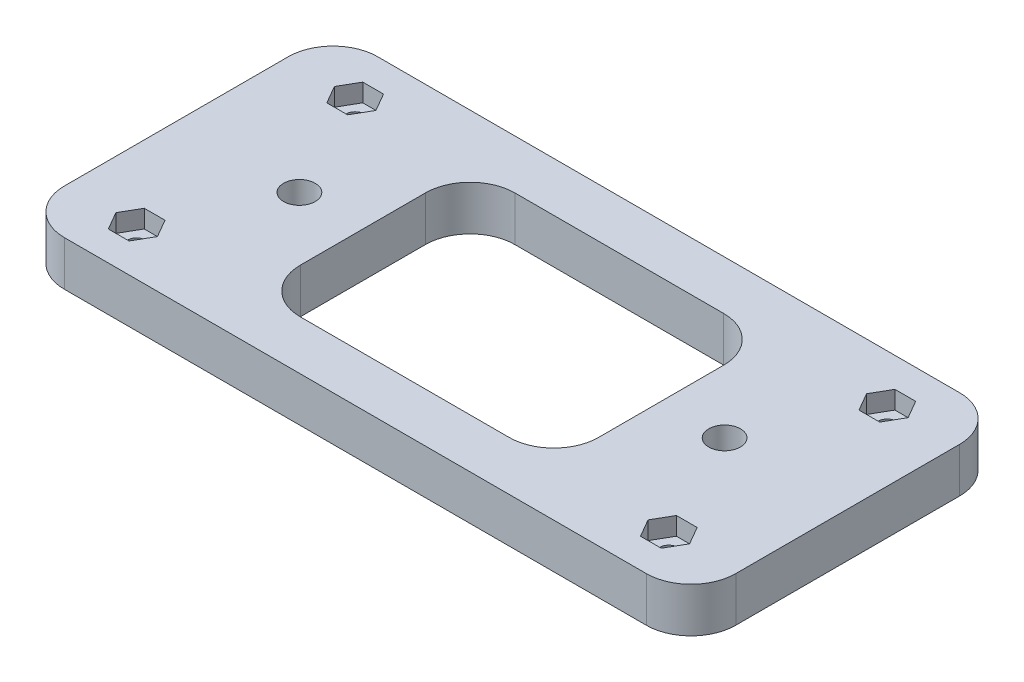
from build123d import *

# Parameters (mm, degrees)
SKETCH1_R                                         = 1.3
BOSS_EXTRUDE1_DEPTH                               = 6.35
CUT_EXTRUDE1_DEPTH                                = 2.55
CSK_FOR_8_FLAT_HEAD_MACHINE_SCREW_100_D           = 4.4958
CSK_FOR_8_FLAT_HEAD_MACHINE_SCREW_100_CSINK_D     = 8.4328
CSK_FOR_8_FLAT_HEAD_MACHINE_SCREW_100_CSINK_ANGLE = 100
CUT_EXTRUDE2_DEPTH                                = 1
CUT_EXTRUDE2_DEPTH_BACK                           = 7.35


with BuildPart() as part:
    # Sketch1 → Boss-Extrude1 (new body)
    with BuildSketch(Plane(origin=(0, 0, 0), x_dir=(1, 0, 0), z_dir=(0, 1, 0))):
        with BuildLine():
            Line((41.275, 22.225), (-41.275, 22.225))
            ThreePointArc((-41.275, 22.225), (-45.765128061, 20.365128061), (-47.625, 15.875))
            Line((-47.625, 15.875), (-47.625, -15.875))
            ThreePointArc((-47.625, -15.875), (-45.765128061, -20.365128061), (-41.275, -22.225))
            Line((-41.275, -22.225), (41.275, -22.225))
            ThreePointArc((41.275, -22.225), (45.765128061, -20.365128061), (47.625, -15.875))
            Line((47.625, -15.875), (47.625, 15.875))
            ThreePointArc((47.625, 15.875), (45.765128061, 20.365128061), (41.275, 22.225))
        make_face()
        with Locations((-37.75, 15.5)):
            Circle(SKETCH1_R, mode=Mode.SUBTRACT)
        with Locations((37.75, 15.5)):
            Circle(SKETCH1_R, mode=Mode.SUBTRACT)
        with Locations((37.75, -15.5)):
            Circle(SKETCH1_R, mode=Mode.SUBTRACT)
        with Locations((-37.75, -15.5)):
            Circle(SKETCH1_R, mode=Mode.SUBTRACT)
    extrude(amount=BOSS_EXTRUDE1_DEPTH)

    # Sketch2 → Cut-Extrude1 (cut)
    with BuildSketch(Plane(origin=(0, 6.35, 0), x_dir=(1, 0, 0), z_dir=(0, 1, 0))):
        Polygon((-34.805513627, 15.5), (-36.277756814, 18.05), (-39.222243186, 18.05), (-40.694486373, 15.5), (-39.222243186, 12.95), (-36.277756814, 12.95), align=None)
        Polygon((36.277756814, 12.95), (34.805513627, 15.5), (36.277756814, 18.05), (39.222243186, 18.05), (40.694486373, 15.5), (39.222243186, 12.95), align=None)
        Polygon((34.805513627, -15.5), (36.277756814, -18.05), (39.222243186, -18.05), (40.694486373, -15.5), (39.222243186, -12.95), (36.277756814, -12.95), align=None)
        Polygon((-36.277756814, -12.95), (-34.805513627, -15.5), (-36.277756814, -18.05), (-39.222243186, -18.05), (-40.694486373, -15.5), (-39.222243186, -12.95), align=None)
    extrude(amount=-CUT_EXTRUDE1_DEPTH, mode=Mode.SUBTRACT)

    # CSK for #8 Flat Head Machine Screw (100)4 (through all)
    with Locations(Plane(origin=(0, 0, 0), x_dir=(-1, 0, 0), z_dir=(0, -1, 0))):
        with Locations((30.1625, 0), (-30.1625, 0)):
            CounterSinkHole(CSK_FOR_8_FLAT_HEAD_MACHINE_SCREW_100_D / 2, CSK_FOR_8_FLAT_HEAD_MACHINE_SCREW_100_CSINK_D / 2, counter_sink_angle=CSK_FOR_8_FLAT_HEAD_MACHINE_SCREW_100_CSINK_ANGLE)

    # Sketch6 → Cut-Extrude2 (cut, two sides)
    with BuildSketch(Plane.XZ) as cut_extrude2_sk:
        with BuildLine():
            Line((-14.8125, -15.225), (14.8125, -15.225))
            ThreePointArc((14.8125, -15.225), (19.302628061, -13.365128061), (21.1625, -8.875))
            Line((21.1625, -8.875), (21.1625, 8.875))
            ThreePointArc((21.1625, 8.875), (19.302628061, 13.365128061), (14.8125, 15.225))
            Line((14.8125, 15.225), (-14.8125, 15.225))
            ThreePointArc((-14.8125, 15.225), (-19.302628061, 13.365128061), (-21.1625, 8.875))
            Line((-21.1625, 8.875), (-21.1625, -8.875))
            ThreePointArc((-21.1625, -8.875), (-19.302628061, -13.365128061), (-14.8125, -15.225))
        make_face()
    extrude(amount=CUT_EXTRUDE2_DEPTH, mode=Mode.SUBTRACT)
    extrude(cut_extrude2_sk.sketch, amount=-CUT_EXTRUDE2_DEPTH_BACK, mode=Mode.SUBTRACT)


solid = part.part
